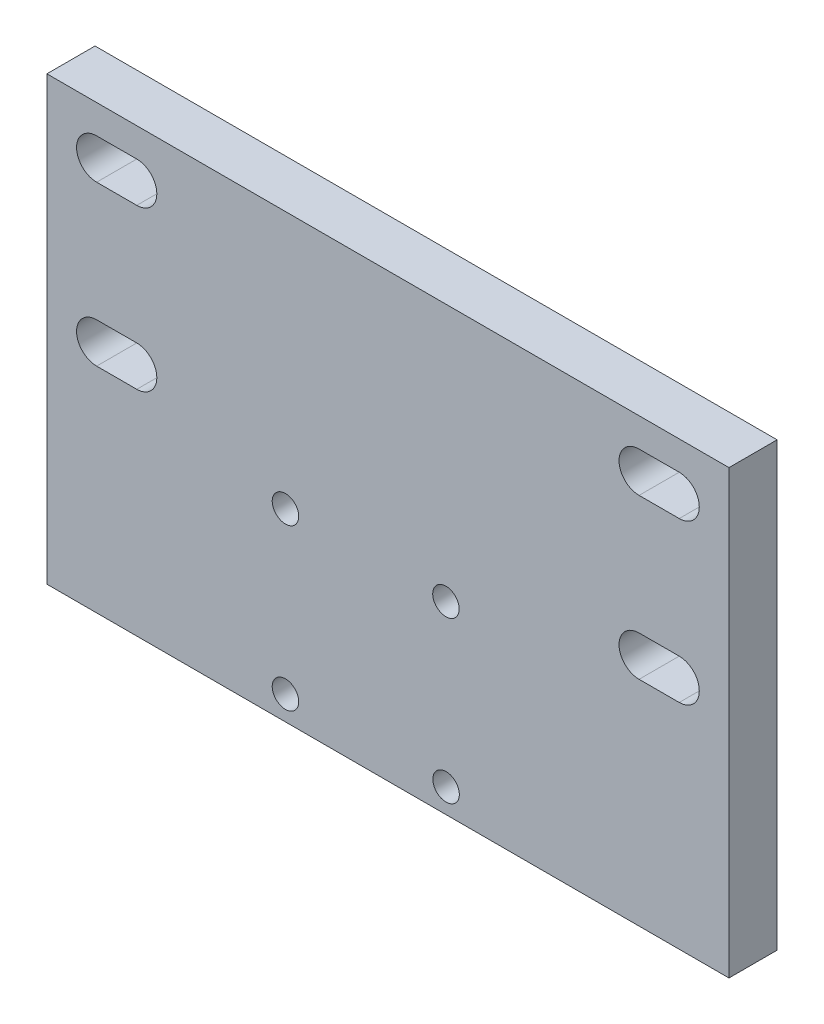
from build123d import *

# Parameters (mm, degrees)
SKETCH2_W           = 85
SKETCH2_H           = 55.083692651
SKETCH2_R           = 1.65
BOSS_EXTRUDE1_DEPTH = 6


with BuildPart() as part:
    # Sketch2 → Boss-Extrude1 (new body)
    with BuildSketch(Plane.XY):
        with Locations((2.5, -11.594499981)):
            Rectangle(SKETCH2_W, SKETCH2_H)
        with Locations((-10.268789461, -16.131613602)):
            Circle(SKETCH2_R, mode=Mode.SUBTRACT)
        with Locations((9.731210539, -16.131613602)):
            Circle(SKETCH2_R, mode=Mode.SUBTRACT)
        with Locations((-10.268789461, -36.131613602)):
            Circle(SKETCH2_R, mode=Mode.SUBTRACT)
        with Locations((9.747732282, -36.131613602)):
            Circle(SKETCH2_R, mode=Mode.SUBTRACT)
        with BuildLine():
            Line((-33.8, 12.35), (-28.8, 12.35))
            ThreePointArc((-28.8, 12.35), (-26.3, 9.85), (-28.8, 7.35))
            Line((-28.8, 7.35), (-33.8, 7.35))
            ThreePointArc((-33.8, 7.35), (-36.3, 9.85), (-33.8, 12.35))
        make_face(mode=Mode.SUBTRACT)
        with BuildLine():
            Line((-33.8, -7.5), (-28.8, -7.5))
            ThreePointArc((-28.8, -7.5), (-26.3, -10), (-28.8, -12.5))
            Line((-28.8, -12.5), (-33.8, -12.5))
            ThreePointArc((-33.8, -12.5), (-36.3, -10), (-33.8, -7.5))
        make_face(mode=Mode.SUBTRACT)
        with BuildLine():
            Line((38.8, 12.35), (33.8, 12.35))
            ThreePointArc((33.8, 12.35), (31.3, 9.85), (33.8, 7.35))
            Line((33.8, 7.35), (38.8, 7.35))
            ThreePointArc((38.8, 7.35), (41.3, 9.85), (38.8, 12.35))
        make_face(mode=Mode.SUBTRACT)
        with BuildLine():
            Line((38.8, -7.5), (33.8, -7.5))
            ThreePointArc((33.8, -7.5), (31.3, -10), (33.8, -12.5))
            Line((33.8, -12.5), (38.8, -12.5))
            ThreePointArc((38.8, -12.5), (41.3, -10), (38.8, -7.5))
        make_face(mode=Mode.SUBTRACT)
    extrude(amount=BOSS_EXTRUDE1_DEPTH)


solid = part.part
